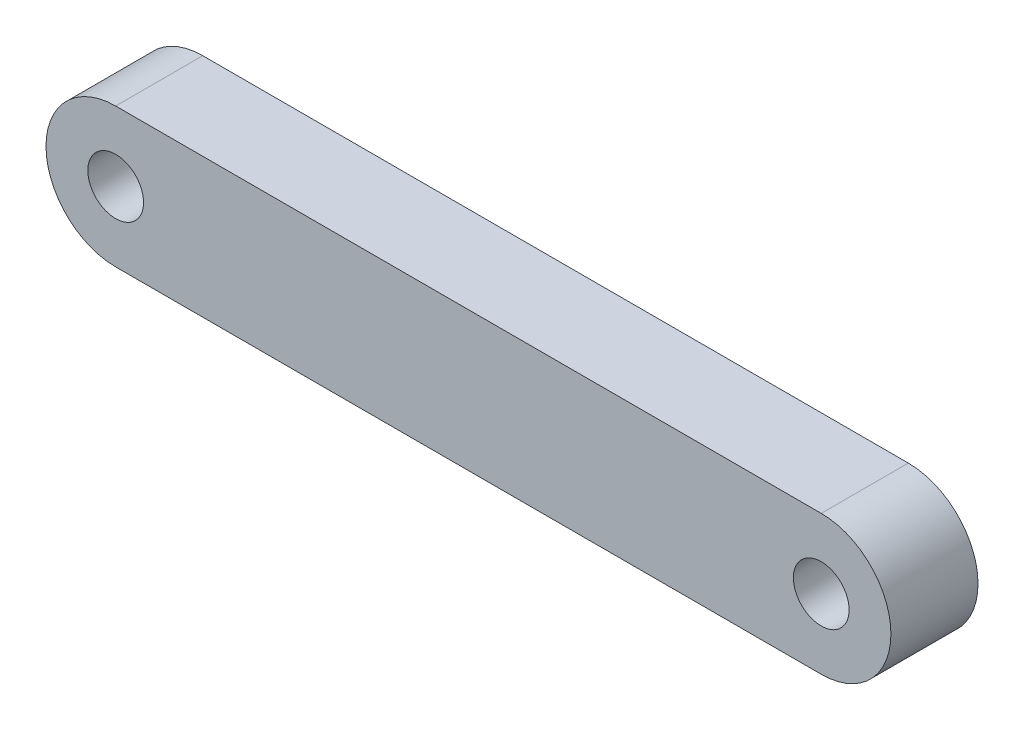
from build123d import *

# Parameters (mm, degrees)
BOSS_EXTRU_1_DEPTH      = 5
ESQUISSE3_R             = 1.6
ENL_V_MAT_EXTRU_2_DEPTH = 6


with BuildPart() as part:
    # Esquisse1 → Boss.-Extru.1 (new body)
    with BuildSketch(Plane.XY):
        with BuildLine():
            Line((4, 0), (44.5, 0))
            ThreePointArc((44.5, 0), (48.5, 4), (44.5, 8))
            Line((44.5, 8), (4, 8))
            ThreePointArc((4, 8), (0, 4), (4, 0))
        make_face()
    extrude(amount=BOSS_EXTRU_1_DEPTH)

    # Esquisse3 → Enlèv. mat.-Extru.2 (cut, through all)
    with BuildSketch(Plane.XY):
        with Locations((4, 4)):
            Circle(ESQUISSE3_R)
        with Locations((44.5, 4)):
            Circle(ESQUISSE3_R)
    extrude(amount=ENL_V_MAT_EXTRU_2_DEPTH, mode=Mode.SUBTRACT)


solid = part.part
